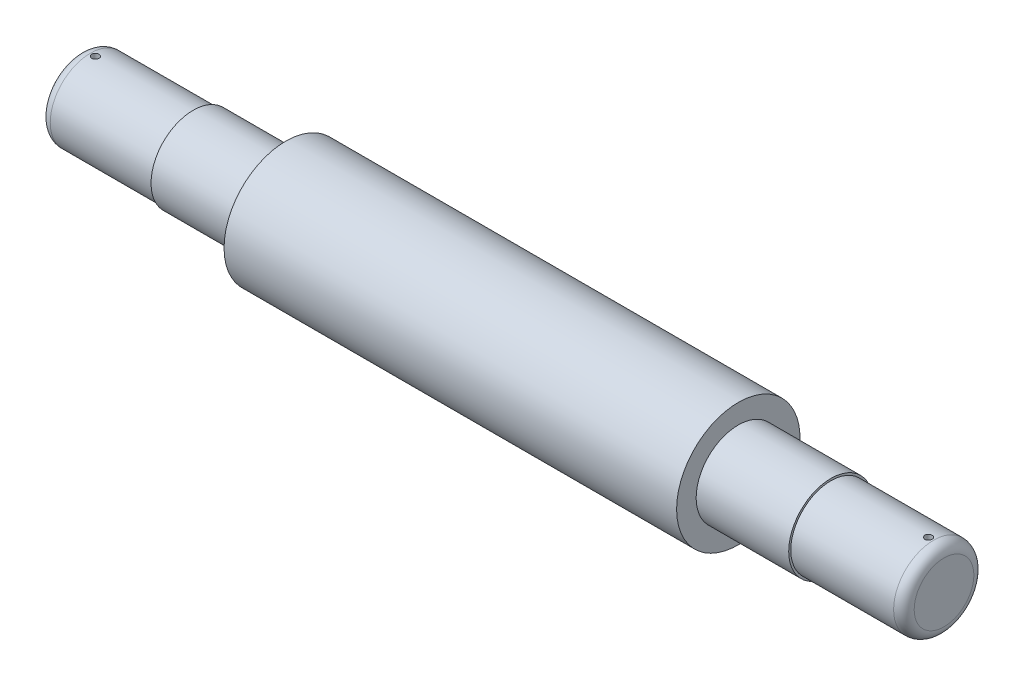
from build123d import *

# Parameters (mm, degrees)
RADYUS1_R             = 10
IZIM2_R               = 3.75
KES_EKSTR_ZYON1_DEPTH = 10
RADYUS2_R             = 10
IZIM3_R               = 3.5
KES_EKSTR_ZYON2_DEPTH = 100.511524539


with BuildPart() as part:
    # Çizim1 → Döndür1 (revolve)
    with BuildSketch(Plane.XY):
        Polygon((158.555065461, 64.488475461), (158.555065461, 62.488475461), (48.555065461, 62.488475461), (48.555065461, 23.488475461), (888.555065461, 23.488475461), (888.555065461, 62.488475461), (778.555065461, 62.488475461), (778.555065461, 64.488475461), (688.555065461, 64.488475461), (688.555065461, 83.488475461), (248.555065461, 83.488475461), (248.555065461, 64.488475461), align=None)
    revolve(axis=Axis((48.555065461, 23.488475461, 0), (1, 0, 0)))

    # Radyus1
    radyus1_edges = [part.edges().sort_by_distance(p)[0] for p in [
        (48.555065461, -15.511524539, 0),
    ]]
    fillet(radyus1_edges, radius=RADYUS1_R)

    # Çizim2 → Kes-Ekstrüzyon1 (cut)
    with BuildSketch(Plane.ZY.offset(-48.555065461)):
        with Locations((0, 23.488475461)):
            Circle(IZIM2_R)
    extrude(amount=-KES_EKSTR_ZYON1_DEPTH, mode=Mode.SUBTRACT)

    # Radyus2
    radyus2_edges = [part.edges().sort_by_distance(p)[0] for p in [
        (888.555065461, -15.511524539, 0),
    ]]
    fillet(radyus2_edges, radius=RADYUS2_R)

    # Çizim3 → Kes-Ekstrüzyon2 (cut, through all)
    with BuildSketch(Plane(origin=(0, 63, 0), x_dir=(1, 0, 0), z_dir=(0, 1, 0))):
        with Locations((63.555065461, 0)):
            Circle(IZIM3_R)
        with Locations((873.555065461, 0)):
            Circle(IZIM3_R)
    extrude(amount=-KES_EKSTR_ZYON2_DEPTH, mode=Mode.SUBTRACT)


solid = part.part
